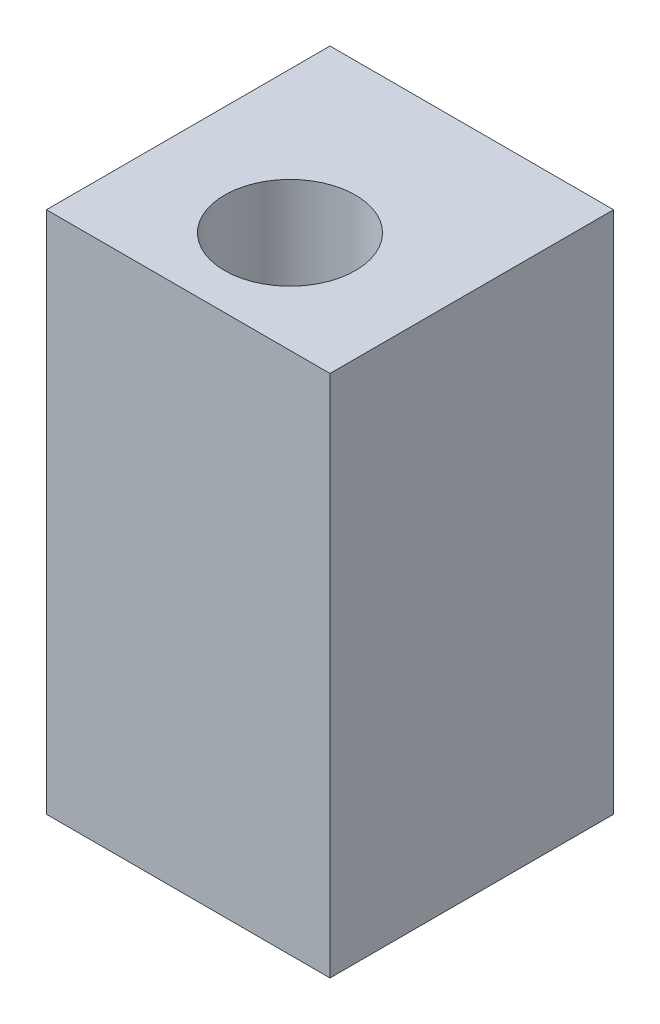
from build123d import *

# Parameters (mm, degrees)
SKETCH2_W           = 9.75
SKETCH2_H           = 9.75
BOSS_EXTRUDE1_DEPTH = 18
SKETCH3_R           = 2.25
CUT_EXTRUDE1_DEPTH  = 21


with BuildPart() as part:
    # Sketch2 → Boss-Extrude1 (new body)
    with BuildSketch(Plane(origin=(0, 0, 0), x_dir=(1, 0, 0), z_dir=(0, 1, 0))):
        Rectangle(SKETCH2_W, SKETCH2_H)
    extrude(amount=BOSS_EXTRUDE1_DEPTH)

    # Sketch3 → Cut-Extrude1 (cut)
    with BuildSketch(Plane(origin=(0, 18, 0), x_dir=(1, 0, 0), z_dir=(0, 1, 0))):
        with Locations((0, -1.375)):
            Circle(SKETCH3_R)
    extrude(amount=-CUT_EXTRUDE1_DEPTH, mode=Mode.SUBTRACT)


solid = part.part
